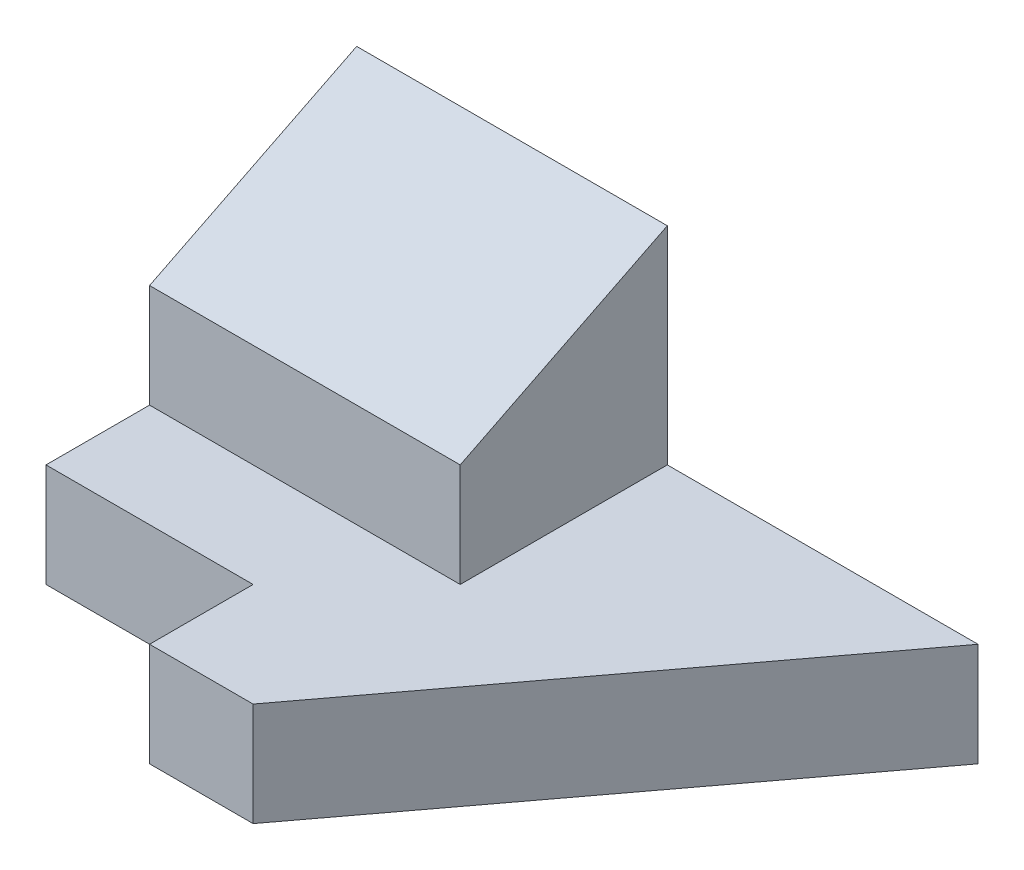
from build123d import *

# Parameters (mm, degrees)
EXTRUDE_1_DEPTH     = 5
SKETCH_1_3_W        = 15
SKETCH_1_3_H        = 10
EXTRUDE_2_DEPTH     = 15
CUT_EXTRUDE_1_DEPTH = 15


with BuildPart() as part:
    # 草圖1 → 填料-伸長1 (new body)
    with BuildSketch(Plane(origin=(0, 0, 0), x_dir=(1, 0, 0), z_dir=(0, 1, 0))):
        Polygon((-5, -10), (0, -10), (15, 10), (-15, 10), (-15, -5), (-5, -5), align=None)
    extrude(amount=EXTRUDE_1_DEPTH)

    # 草圖1<3> → 填料-伸長2 (add)
    with BuildSketch(Plane(origin=(0, 0, 0), x_dir=(1, 0, 0), z_dir=(0, 1, 0))):
        with Locations((-7.5, 5)):
            Rectangle(SKETCH_1_3_W, SKETCH_1_3_H)
    extrude(amount=EXTRUDE_2_DEPTH)

    # 草圖2 → 除料-伸長1 (cut)
    with BuildSketch(Plane(origin=(0, 0, 0), x_dir=(0, 0, -1), z_dir=(1, 0, 0))):
        Polygon((10, 15), (0, 10), (0, 15), align=None)
    extrude(amount=-CUT_EXTRUDE_1_DEPTH, mode=Mode.SUBTRACT)


solid = part.part
